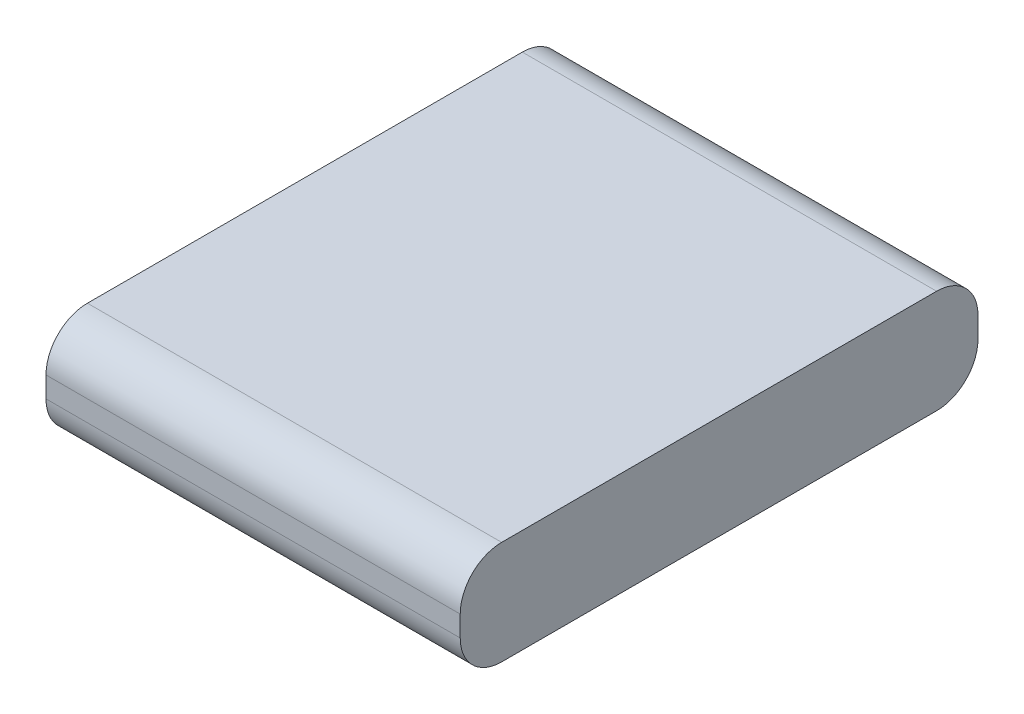
from build123d import *

# Parameters (mm, degrees)
SKETCH1_W           = 400
SKETCH1_H           = 100
BOSS_EXTRUDE1_DEPTH = 500
FILLET2_R           = 40


with BuildPart() as part:
    # Sketch1 → Boss-Extrude1 (new body)
    with BuildSketch(Plane.XY):
        with Locations((200, -50)):
            Rectangle(SKETCH1_W, SKETCH1_H)
    extrude(amount=BOSS_EXTRUDE1_DEPTH)

    # Fillet2
    fillet2_edges = [part.edges().sort_by_distance(p)[0] for p in [
        (200, 0, 500),
        (200, 0, 0),
        (200, -100, 0),
        (200, -100, 500),
    ]]
    fillet(fillet2_edges, radius=FILLET2_R)


solid = part.part
